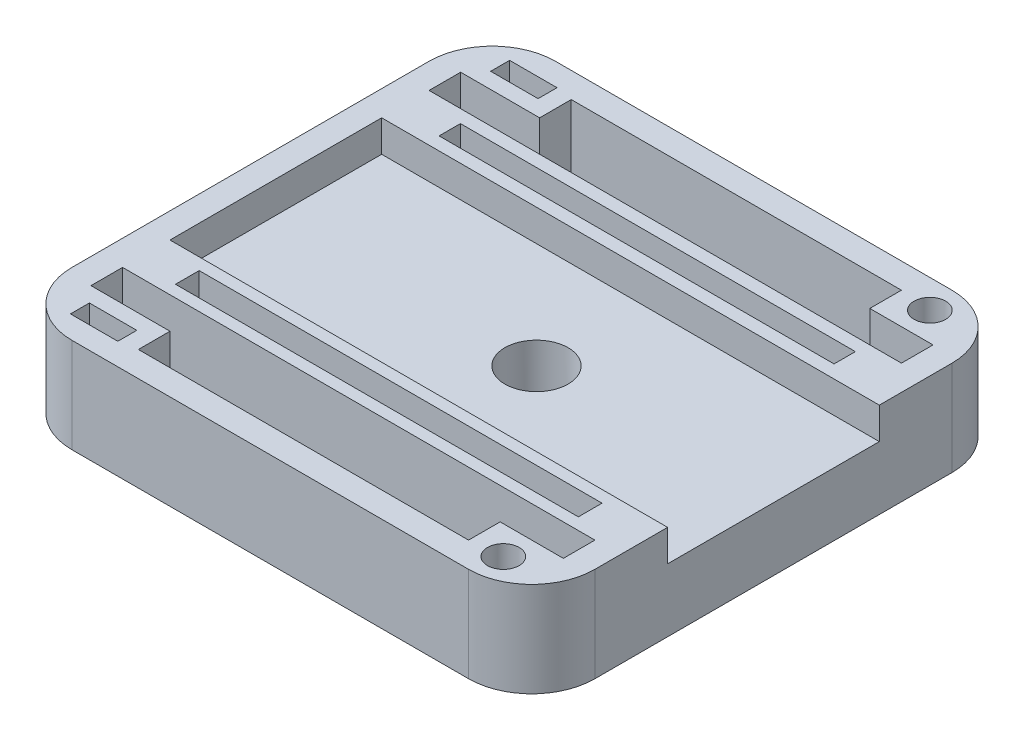
from build123d import *

# Parameters (mm, degrees)
BOSS_EXTRUDE1_DEPTH      = 5.08
BOSS_EXTRUDE1_DEPTH_BACK = 5.08
SKETCH1_W                = 84.074
SKETCH1_H                = 77.724
BOSS_EXTRUDE2_DEPTH      = 5.08
BOSS_EXTRUDE2_DEPTH_BACK = 10.16
SKETCH2_W                = 84.074
SKETCH2_H                = 77.724
CUT_EXTRUDE1_DEPTH       = 59.14284146
CUT_EXTRUDE1_DEPTH_BACK  = 59.14284146
SKETCH3_W                = 53.086
SKETCH3_H                = 5.08
CUT_EXTRUDE2_DEPTH       = 59.14284146
CUT_EXTRUDE2_DEPTH_BACK  = 59.14284146
SKETCH4_W                = 75.946
SKETCH4_H                = 5.08
BOSS_EXTRUDE3_DEPTH      = 5.08
BOSS_EXTRUDE3_DEPTH_BACK = 10.16
SKETCH5_W                = 75.946
SKETCH5_H                = 7.62
CUT_EXTRUDE4_DEPTH       = 59.14284146
CUT_EXTRUDE4_DEPTH_BACK  = 59.14284146
SKETCH10_R               = 5.08
FILLET1_R                = 10.16
SKETCH15_R               = 2.54
SKETCH15_W               = 7.62
SKETCH15_H               = 3.048
CUT_EXTRUDE6_DEPTH       = 60.242062869
SKETCH7_W                = 34.036
SKETCH7_H                = 5.08
CUT_EXTRUDE7_DEPTH       = 90.526983329
SKETCH14_W               = 64.77
SKETCH14_H               = 3.81
SKETCH14_W_2             = 63.5
SKETCH14_H_2             = 3.429
CUT_EXTRUDE8_DEPTH       = 3.81


with BuildPart() as part:
    # Sketch1 → Boss-Extrude1 (new, two sides: drawn at the far end of the back side and taken through both)
    with BuildSketch(Plane(origin=(0, 0, 0), x_dir=(1, 0, 0), z_dir=(0, 1, 0)).offset(-BOSS_EXTRUDE1_DEPTH_BACK)):
        Rectangle(SKETCH1_W, SKETCH1_H)
    extrude(amount=BOSS_EXTRUDE1_DEPTH + BOSS_EXTRUDE1_DEPTH_BACK)

    # Sketch2 → Boss-Extrude2 (add, two sides: drawn at the far end of the back side and taken through both)
    with BuildSketch(Plane(origin=(0, 5.08, 0), x_dir=(1, 0, 0), z_dir=(0, 1, 0)).offset(-BOSS_EXTRUDE2_DEPTH_BACK)):
        Rectangle(SKETCH2_W, SKETCH2_H)
        Polygon((-25.273, 34.798), (27.813, 34.798), (27.813, 29.718), (37.973, 29.718), (37.973, -29.718), (27.813, -29.718), (27.813, -34.798), (-25.273, -34.798), (-25.273, -29.718), (-37.973, -29.718), (-37.973, 29.718), (-25.273, 29.718), align=None, mode=Mode.SUBTRACT)
    extrude(amount=BOSS_EXTRUDE2_DEPTH + BOSS_EXTRUDE2_DEPTH_BACK)

    # Sketch3 → Cut-Extrude1 (cut, two sides: drawn at the far end of the back side and taken through both)
    with BuildSketch(Plane(origin=(0, 5.08, 0), x_dir=(1, 0, 0), z_dir=(0, 1, 0)).offset(-CUT_EXTRUDE1_DEPTH_BACK)):
        with Locations((1.27, 32.258)):
            Rectangle(SKETCH3_W, SKETCH3_H)
        with Locations((1.27, -32.258)):
            Rectangle(SKETCH3_W, SKETCH3_H)
    extrude(amount=CUT_EXTRUDE1_DEPTH + CUT_EXTRUDE1_DEPTH_BACK, mode=Mode.SUBTRACT)

    # Sketch4 → Cut-Extrude2 (cut, two sides: drawn at the far end of the back side and taken through both)
    with BuildSketch(Plane(origin=(0, 5.08, 0), x_dir=(1, 0, 0), z_dir=(0, 1, 0)).offset(-CUT_EXTRUDE2_DEPTH_BACK)):
        with Locations((0, 27.178)):
            Rectangle(SKETCH4_W, SKETCH4_H)
        with Locations((0, -27.178)):
            Rectangle(SKETCH4_W, SKETCH4_H)
    extrude(amount=CUT_EXTRUDE2_DEPTH + CUT_EXTRUDE2_DEPTH_BACK, mode=Mode.SUBTRACT)

    # Sketch5 → Boss-Extrude3 (add, two sides: drawn at the far end of the back side and taken through both)
    with BuildSketch(Plane(origin=(0, 5.08, 0), x_dir=(1, 0, 0), z_dir=(0, 1, 0)).offset(-BOSS_EXTRUDE3_DEPTH_BACK)):
        with Locations((0, 20.828)):
            Rectangle(SKETCH5_W, SKETCH5_H)
        with Locations((0, -20.828)):
            Rectangle(SKETCH5_W, SKETCH5_H)
    extrude(amount=BOSS_EXTRUDE3_DEPTH + BOSS_EXTRUDE3_DEPTH_BACK)

    # Sketch10 → Cut-Extrude4 (cut, two sides: drawn at the far end of the back side and taken through both)
    with BuildSketch(Plane(origin=(0, 5.08, 0), x_dir=(1, 0, 0), z_dir=(0, 1, 0)).offset(-CUT_EXTRUDE4_DEPTH_BACK)):
        with Locations((3.937, 0)):
            Circle(SKETCH10_R)
    extrude(amount=CUT_EXTRUDE4_DEPTH + CUT_EXTRUDE4_DEPTH_BACK, mode=Mode.SUBTRACT)

    # Fillet1
    fillet1_edges = [part.edges().sort_by_distance(p)[0] for p in [
        (42.037, 2.54, -38.862),
        (-42.037, 2.54, -38.862),
        (-42.037, 2.54, 38.862),
        (42.037, 2.54, 38.862),
    ]]
    fillet(fillet1_edges, radius=FILLET1_R)

    # Sketch15 → Cut-Extrude6 (cut, symmetric)
    with BuildSketch(Plane(origin=(0, 10.16, 0), x_dir=(1, 0, 0), z_dir=(0, 1, 0))):
        with Locations((32.893, 34.29)):
            Circle(SKETCH15_R)
        with Locations((-31.877, 33.782)):
            Rectangle(SKETCH15_W, SKETCH15_H)
    cut_extrude6 = extrude(amount=CUT_EXTRUDE6_DEPTH, both=True, mode=Mode.SUBTRACT)

    # Mirror1: Cut-Extrude6 across plane
    add(cut_extrude6.mirror(Plane.XY), mode=Mode.SUBTRACT)

    # Sketch7 → Cut-Extrude7 (cut, through all)
    with BuildSketch(Plane.ZY.offset(-37.973)):
        with Locations((0, 7.62)):
            Rectangle(SKETCH7_W, SKETCH7_H)
    extrude(amount=-CUT_EXTRUDE7_DEPTH, mode=Mode.SUBTRACT)

    # Sketch14 → Cut-Extrude8 (cut)
    with BuildSketch(Plane(origin=(0, 10.16, 0), x_dir=(1, 0, 0), z_dir=(0, 1, 0))):
        with Locations((1.015527002, -20.828)):
            Rectangle(SKETCH14_W, SKETCH14_H)
        with Locations((0.914410511, 20.828)):
            Rectangle(SKETCH14_W_2, SKETCH14_H_2)
    extrude(amount=-CUT_EXTRUDE8_DEPTH, mode=Mode.SUBTRACT)


solid = part.part
